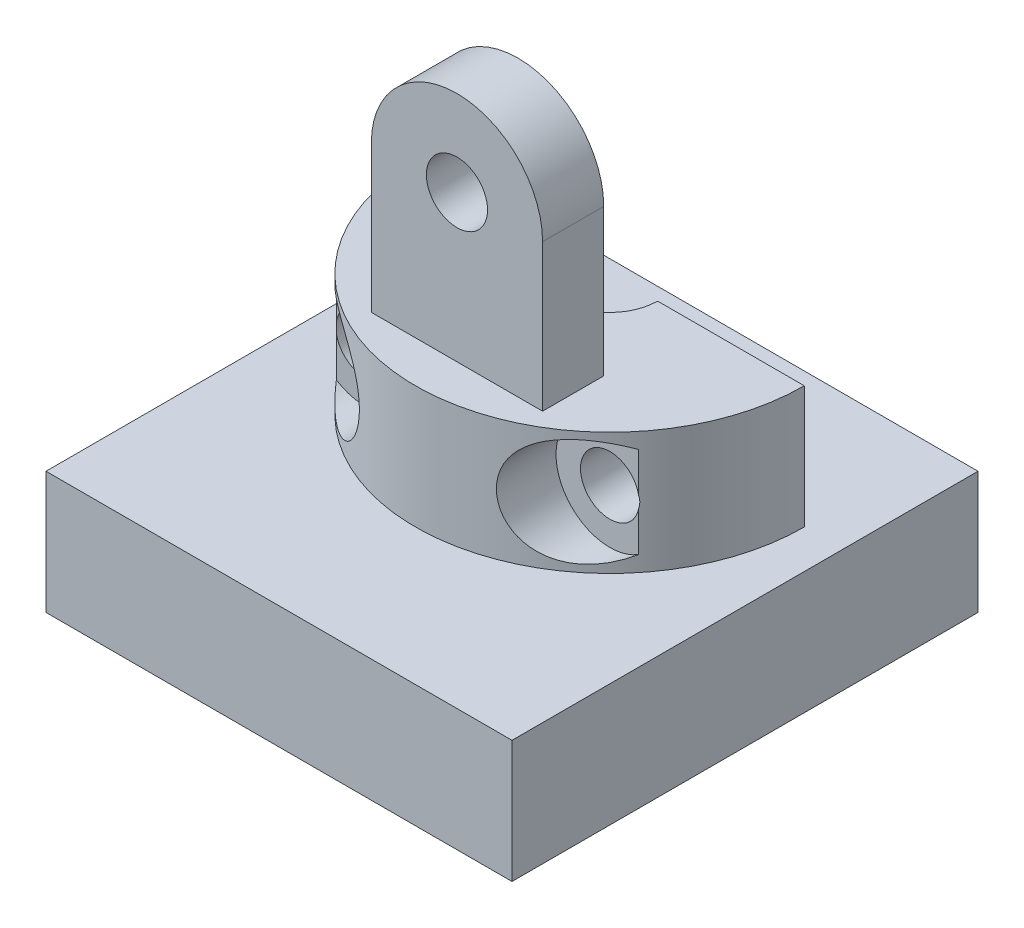
from build123d import *

# Parameters (mm, degrees)
BOSS_EXTRUDE1_DEPTH           = 2.5
SKETCH2_W                     = 7
SKETCH2_H                     = 2.5
BOSS_EXTRUDE2_DEPTH           = 9.5
CUT_EXTRUDE1_DEPTH            = 9.5
SKETCH4_R                     = 1.25
CUT_EXTRUDE2_DEPTH            = 9.5
CBORE_FOR_M2_SHCS1_AT_2_COUNT = 2
CBORE_FOR_M2_SHCS1_AT_2_PITCH = 10
SKETCH8_R                     = 2.2
CUT_EXTRUDE3_DEPTH            = 9.5
SKETCH11_W                    = 19.05
SKETCH11_H                    = 19.05
BOSS_EXTRUDE3_DEPTH           = 5
FILLET1_R                     = 0.07


with BuildPart() as part:
    # Sketch1 → Boss-Extrude1 (new body, symmetric)
    with BuildSketch(Plane(origin=(0, 0, 0), x_dir=(1, 0, 0), z_dir=(0, 1, 0))):
        with BuildLine():
            Line((1.95, 0), (7.9492, 0))
            ThreePointArc((7.9492, 0), (0, -7.9492), (-7.9492, 0))
            Line((-7.9492, 0), (-1.95, 0))
            ThreePointArc((-1.95, 0), (0, -1.95), (1.95, 0))
        make_face()
    extrude(amount=BOSS_EXTRUDE1_DEPTH, both=True)

    # Sketch2 → Boss-Extrude2 (add)
    with BuildSketch(Plane(origin=(0, 2.5, 0), x_dir=(1, 0, 0), z_dir=(0, 1, 0))):
        with Locations((0, -5)):
            Rectangle(SKETCH2_W, SKETCH2_H)
    extrude(amount=BOSS_EXTRUDE2_DEPTH)

    # Sketch3 → Cut-Extrude1 (cut)
    with BuildSketch(Plane(origin=(0, 0, 3.75), x_dir=(-1, 0, 0), z_dir=(0, 0, -1))):
        with BuildLine():
            Line((-3.5, 8.5), (-3.5, 14.886359519))
            Line((-3.5, 14.886359519), (0, 16.809201746))
            Line((0, 16.809201746), (3.5, 14.5))
            Line((3.5, 14.5), (3.5, 8.5))
            ThreePointArc((3.5, 8.5), (0, 12), (-3.5, 8.5))
        make_face()
    extrude(amount=-CUT_EXTRUDE1_DEPTH, mode=Mode.SUBTRACT)

    # Sketch4 → Cut-Extrude2 (cut)
    with BuildSketch(Plane(origin=(0, 0, 3.75), x_dir=(-1, 0, 0), z_dir=(0, 0, -1))):
        with Locations((0, 8.5)):
            Circle(SKETCH4_R)
    extrude(amount=-CUT_EXTRUDE2_DEPTH, mode=Mode.SUBTRACT)

    # Sketch7 → CBORE for M2 SHCS1 (revolve, cut)
    with BuildSketch(Plane(origin=(5, 0, 7), x_dir=(0, -1, 0), z_dir=(1, 0, 0))):
        Polygon((0, 0), (0, 7), (1.2, 7), (1.2, 2), (2.2, 2), (2.2, 0), align=None)
    cbore_for_m2_shcs1 = revolve(axis=Axis((5, 0, 13.35), (0, 0, -1)), mode=Mode.SUBTRACT)

    # CBORE for M2 SHCS1 at 2: CBORE for M2 SHCS1 ×2
    with Locations(*[(-i * CBORE_FOR_M2_SHCS1_AT_2_PITCH, 0, 0) for i in range(1, CBORE_FOR_M2_SHCS1_AT_2_COUNT)]):
        add(cbore_for_m2_shcs1, mode=Mode.SUBTRACT)

    # Sketch8 → Cut-Extrude3 (cut)
    with BuildSketch(Plane(origin=(0, 0, 7), x_dir=(-1, 0, 0), z_dir=(0, 0, -1))):
        with Locations((-5, 0)):
            Circle(SKETCH8_R)
        with Locations((5, 0)):
            Circle(SKETCH8_R)
    extrude(amount=-CUT_EXTRUDE3_DEPTH, mode=Mode.SUBTRACT)

    # Sketch11 → Boss-Extrude3 (add)
    with BuildSketch(Plane.XZ.offset(2.5)):
        with Locations((0, 4)):
            Rectangle(SKETCH11_W, SKETCH11_H)
    extrude(amount=BOSS_EXTRUDE3_DEPTH)

    # Fillet1
    fillet1_edges = [part.edges().sort_by_distance(p)[0] for p in [
        (1.95, 0, 0),
        (-1.95, 0, 0),
    ]]
    fillet(fillet1_edges, radius=FILLET1_R)


solid = part.part
